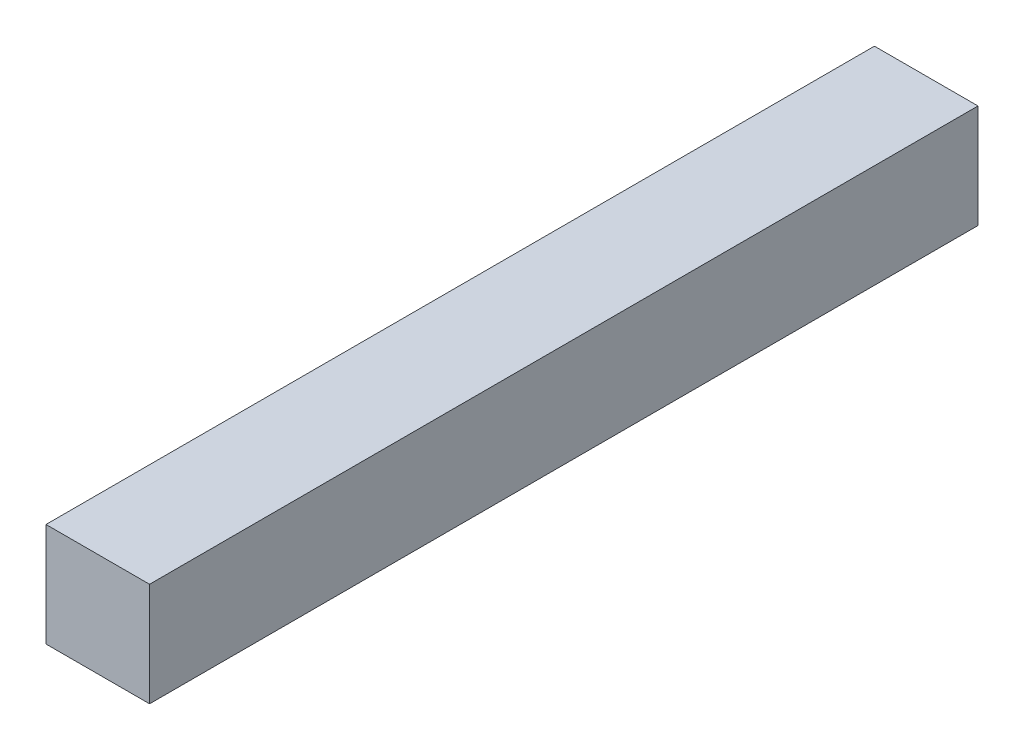
from build123d import *

# Parameters (mm, degrees)
SKETCH1_W           = 38.1
SKETCH1_H           = 38.1
BOSS_EXTRUDE1_DEPTH = 304.8


with BuildPart() as part:
    # Sketch1 → Boss-Extrude1 (new body)
    with BuildSketch(Plane.XY):
        Rectangle(SKETCH1_W, SKETCH1_H)
    extrude(amount=-BOSS_EXTRUDE1_DEPTH)


solid = part.part
